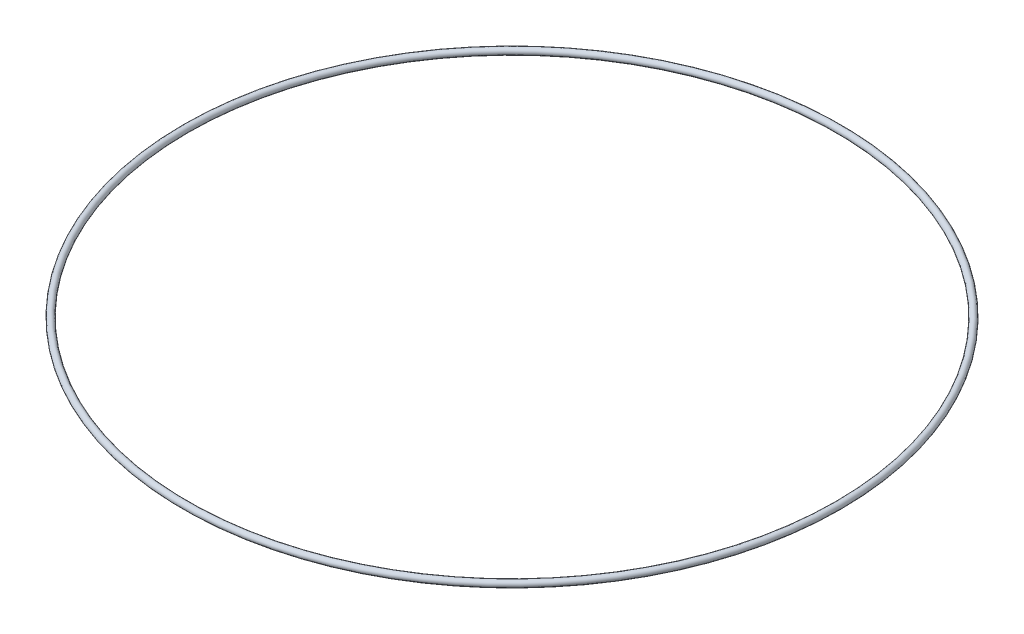
from build123d import *

# Parameters (mm, degrees)
SKETCH5_R = 0.05


with BuildPart() as part:
    # Sweep1: sweep along a path in Sketch1
    with BuildLine(Plane(origin=(0, 0, 0), x_dir=(1, 0, 0), z_dir=(0, 1, 0))) as sweep1_path:
        CenterArc((0, 0), 5, 0, 360)
    # Sketch5 → Sweep1 (sweep)
    with BuildSketch(Plane.XY):
        with Locations((-5, 0)):
            Circle(SKETCH5_R)
    sweep(path=sweep1_path.line)


solid = part.part
